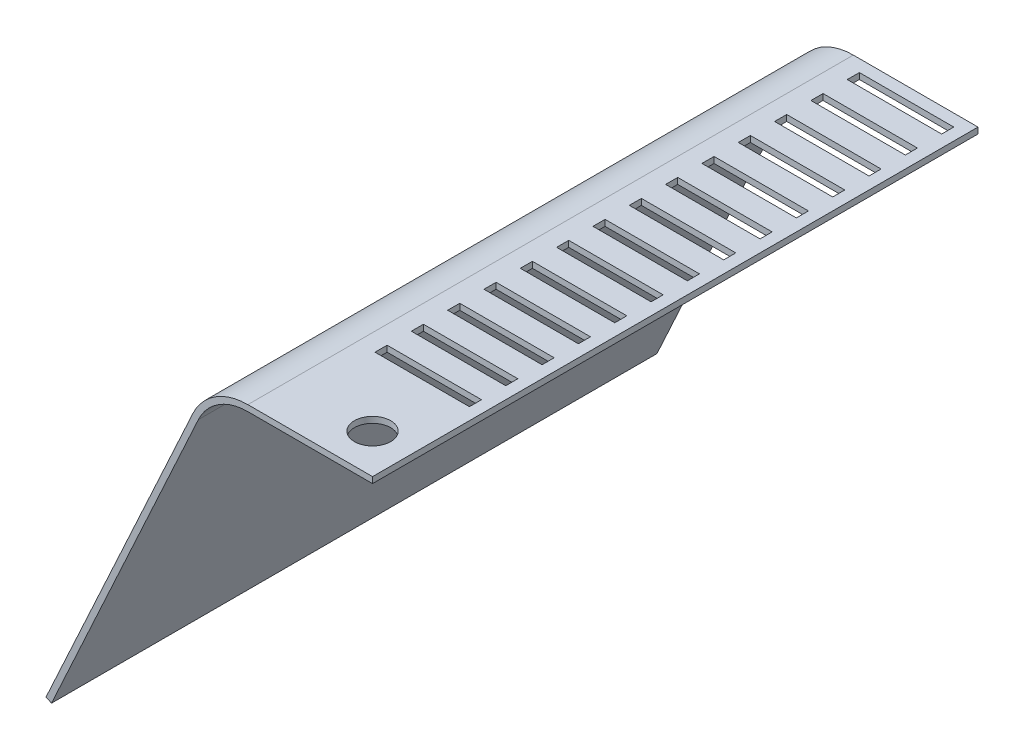
from build123d import *

# Parameters (mm, degrees)
EXTRUDE_THIN1_DEPTH = 500
SKETCH2_W           = 155.95
SKETCH2_H           = 20
CUT_EXTRUDE1_DEPTH  = 590.213534275
LPATTERN1_COUNT     = 14
LPATTERN1_PITCH     = 60
SKETCH3_R           = 30
CUT_EXTRUDE2_DEPTH  = 590.213534275


with BuildPart() as part:
    # Sketch1 → Extrude-Thin1 (new body, symmetric)
    with BuildSketch(Plane.XY):
        with BuildLine():
            Line((0, 0), (-205.95, 0))
            ThreePointArc((-205.95, 0), (-259.885879639, -15.792394123), (-296.786225905, -58.181582248))
            Line((-296.786225905, -58.181582248), (-539.333048865, -585.0316925))
            Line((-539.333048865, -585.0316925), (-530.249426274, -589.213534275))
            Line((-530.249426274, -589.213534275), (-287.702603315, -62.363424024))
            ThreePointArc((-287.702603315, -62.363424024), (-254.492291675, -24.21315471), (-205.95, -10))
            Line((-205.95, -10), (0, -10))
            Line((0, -10), (0, 0))
        make_face()
    extrude(amount=EXTRUDE_THIN1_DEPTH, both=True)

    # Sketch2 → Cut-Extrude1 (cut, through all)
    with BuildSketch(Plane(origin=(0, 0, 0), x_dir=(1, 0, 0), z_dir=(0, 1, 0))):
        with Locations((-97.975, 470)):
            Rectangle(SKETCH2_W, SKETCH2_H)
    cut_extrude1 = extrude(amount=-CUT_EXTRUDE1_DEPTH, mode=Mode.SUBTRACT)

    # LPattern1: Cut-Extrude1 ×14
    with Locations(*[(0, 0, i * LPATTERN1_PITCH) for i in range(1, LPATTERN1_COUNT)]):
        add(cut_extrude1, mode=Mode.SUBTRACT)

    # Sketch3 → Cut-Extrude2 (cut, through all)
    with BuildSketch(Plane(origin=(0, 0, 0), x_dir=(1, 0, 0), z_dir=(0, 1, 0))):
        with Locations((-65, -435)):
            Circle(SKETCH3_R)
    extrude(amount=-CUT_EXTRUDE2_DEPTH, mode=Mode.SUBTRACT)


solid = part.part
